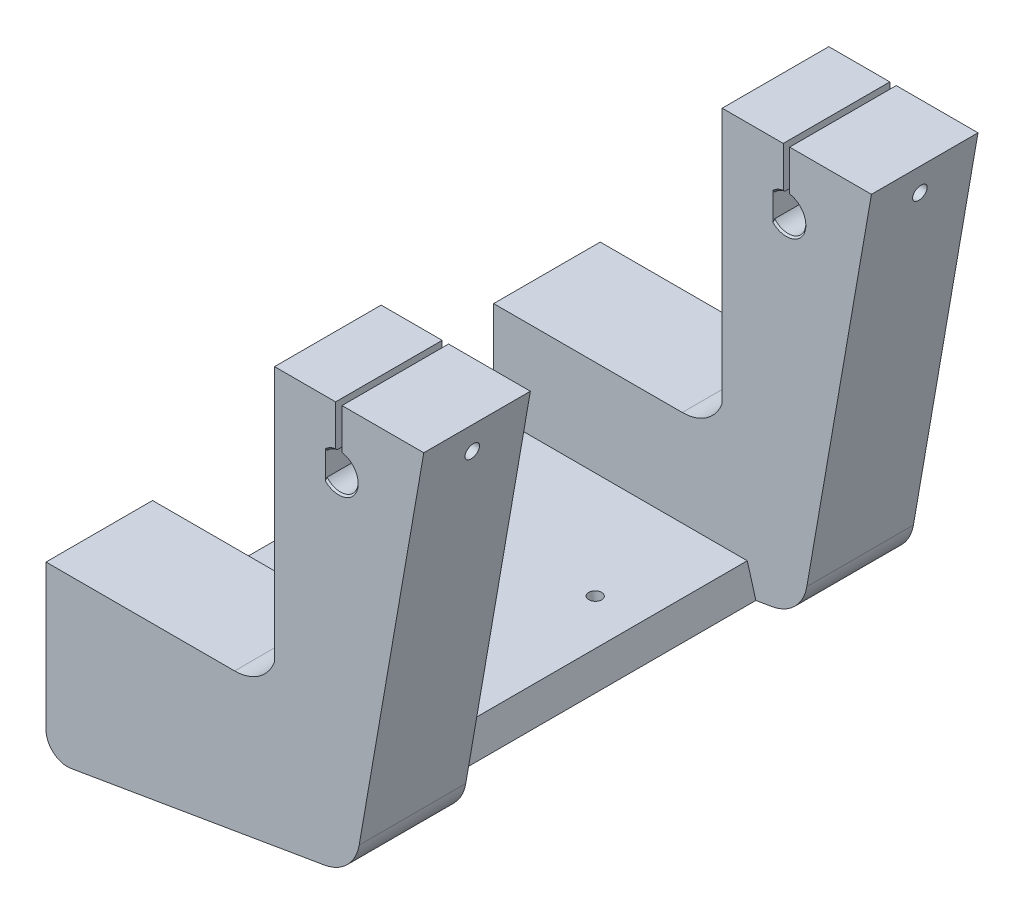
from build123d import *

# Parameters (mm, degrees)
BOSS_EXTRUDE1_DEPTH = 65
CUT_EXTRUDE1_DEPTH  = 40
CUT_EXTRUDE4_DEPTH  = 22.5
SKETCH11_W          = 20
SKETCH11_H          = 25
BOSS_EXTRUDE2_DEPTH = 10
BOSS_EXTRUDE6_DEPTH = 25
BOSS_EXTRUDE7_DEPTH = 25
CUT_EXTRUDE16_DEPTH = 130
SKETCH27_R          = 1.5
CUT_EXTRUDE17_DEPTH = 50
SKETCH28_R          = 1.7
CUT_EXTRUDE18_DEPTH = 50
BOSS_EXTRUDE8_DEPTH = 25
BOSS_EXTRUDE9_DEPTH = 25
CHAMFER9_SIZE       = 0.4
SKETCH31_R          = 1.5
CUT_EXTRUDE19_DEPTH = 10
FILLET1_R           = 0.2


with BuildPart() as part:
    # Sketch1 → Boss-Extrude1 (new body, symmetric)
    with BuildSketch(Plane.XY):
        with BuildLine():
            Line((0, 0), (0, -25.554938316))
            ThreePointArc((0, -25.554938316), (-2.359933303, -32.007021768), (-8.325876175, -35.413807897))
            Line((-8.325876175, -35.413807897), (-67.775097409, -45.508814922))
            ThreePointArc((-67.775097409, -45.508814922), (-71.838201048, -44.399413479), (-73.612159322, -40.579380131))
            Line((-73.612159322, -40.579380131), (-73.612159322, -6.5))
            Line((-73.612159322, -6.5), (-29.367881905, -6.5))
            ThreePointArc((-29.367881905, -6.5), (-23.632117541, -4.691520443), (-19.970955697, 0.079798567))
            Line((-19.970955697, 0.079798567), (-20, 0))
            Line((-20, 0), (0, 0))
        make_face()
    extrude(amount=BOSS_EXTRUDE1_DEPTH, both=True)

    # Sketch2 → Cut-Extrude1 (cut, symmetric)
    with BuildSketch(Plane.XY):
        with BuildLine():
            Line((-20, 0), (-19.970955697, 0.079798567))
            ThreePointArc((-19.970955697, 0.079798567), (-20.672372291, -1.438432196), (-21.617003148, -2.818534521))
            Line((-21.617003148, -2.818534521), (-12.102051753, -36.055036129))
            Line((-12.102051753, -36.055036129), (-8.325876175, -35.413807897))
            ThreePointArc((-8.325876175, -35.413807897), (-2.359933303, -32.007021768), (0, -25.554938316))
            Line((0, -25.554938316), (0, 0))
            Line((0, 0), (-20, 0))
        make_face()
    extrude(amount=CUT_EXTRUDE1_DEPTH, both=True, mode=Mode.SUBTRACT)

    # Sketch5 → Cut-Extrude4 (cut, symmetric)
    with BuildSketch(Plane(origin=(0, -6.5, 0), x_dir=(1, 0, 0), z_dir=(0, 1, 0))):
        Polygon((-73.612159322, 40), (-29.401702386, 40), (0, 40), (0, -40), (-29.367881905, -40), (-73.612159322, -40), align=None)
    extrude(amount=CUT_EXTRUDE4_DEPTH, both=True, mode=Mode.SUBTRACT)

    # Sketch11 → Boss-Extrude2 (add)
    with BuildSketch(Plane(origin=(0, 0, 0), x_dir=(1, 0, 0), z_dir=(0, 1, 0))):
        with Locations((-10, 52.5)):
            Rectangle(SKETCH11_W, SKETCH11_H)
        with Locations((-10, -52.5)):
            Rectangle(SKETCH11_W, SKETCH11_H)
    extrude(amount=BOSS_EXTRUDE2_DEPTH)

    # Sketch24 → Boss-Extrude6 (add)
    with BuildSketch(Plane(origin=(0, 0, -65), x_dir=(-1, 0, 0), z_dir=(0, 0, -1))):
        Polygon((0.147326036, -27.265147592), (-15, 60), (20, 60), (20, 0.001030349), align=None)
    extrude(amount=-BOSS_EXTRUDE6_DEPTH)

    # Sketch25 → Boss-Extrude7 (add)
    with BuildSketch(Plane.XY.offset(65)):
        Polygon((-0.147326036, -27.265147592), (-20, 0.001030349), (-20, 60), (15, 60), align=None)
    extrude(amount=-BOSS_EXTRUDE7_DEPTH)

    # Sketch26 → Cut-Extrude16 (cut)
    with BuildSketch(Plane(origin=(0, 0, -65), x_dir=(-1, 0, 0), z_dir=(0, 0, -1))):
        with BuildLine():
            Line((4.180094607, 50.081666326), (4.180094607, 61.21751544))
            Line((4.180094607, 61.21751544), (5.680094607, 61.21751544))
            Line((5.680094607, 61.21751544), (5.680094607, 50.081666326))
            ThreePointArc((5.680094607, 50.081666326), (4.930094607, 41.85), (4.180094607, 50.081666326))
        make_face()
    extrude(amount=-CUT_EXTRUDE16_DEPTH, mode=Mode.SUBTRACT)

    # Sketch27 → Cut-Extrude17 (cut)
    with BuildSketch(Plane.ZY.offset(20)):
        with Locations((-52.5, 53.5)):
            Circle(SKETCH27_R)
        with Locations((52.5, 53.5)):
            Circle(SKETCH27_R)
    extrude(amount=-CUT_EXTRUDE17_DEPTH, mode=Mode.SUBTRACT)

    # Sketch28 → Cut-Extrude18 (cut)
    with BuildSketch(Plane.ZY.offset(4.180094607)):
        with Locations((52.5, 53.5)):
            Circle(SKETCH28_R)
        with Locations((-52.5, 53.5)):
            Circle(SKETCH28_R)
    extrude(amount=-CUT_EXTRUDE18_DEPTH, mode=Mode.SUBTRACT)

    # Sketch29 → Boss-Extrude8 (add)
    with BuildSketch(Plane.XY.offset(65)):
        with BuildLine():
            Line((-8.080094607, 43.298148783), (-8.080094607, 48.701851217))
            ThreePointArc((-8.080094607, 48.701851217), (-9.080094607, 46), (-8.080094607, 43.298148783))
        make_face()
    extrude(amount=-BOSS_EXTRUDE8_DEPTH)

    # Sketch30 → Boss-Extrude9 (add)
    with BuildSketch(Plane.XY.offset(-40)):
        with BuildLine():
            Line((-8.080094607, 48.701851217), (-8.080094607, 43.298148783))
            ThreePointArc((-8.080094607, 43.298148783), (-9.080094607, 46), (-8.080094607, 48.701851217))
        make_face()
    extrude(amount=-BOSS_EXTRUDE9_DEPTH)

    # Chamfer9
    chamfer9_edges = [part.edges().sort_by_distance(p)[0] for p in [
        (-6.998541472, 49.597780922, 40),
        (-6.998541472, 49.597780922, -40),
        (-1.332313684, 43.931553135, -65),
        (-6.998541472, 49.597780922, 65),
        (-20, 53.5, -54),
        (-20, 53.5, 51),
        (-4.180094607, 53.5, 50.8),
        (-4.180094607, 53.5, -54.2),
        (-1.332313684, 43.931553135, 65),
        (-1.332313684, 43.931553135, 40),
        (-1.332313684, 43.931553135, -40),
        (-6.998541472, 49.597780922, -65),
    ]]
    chamfer(chamfer9_edges, length=CHAMFER9_SIZE)

    # Sketch31 → Cut-Extrude19 (cut)
    with BuildSketch(Plane(origin=(5.611689276, -33.047085202, 0), x_dir=(0.985886958, 0.167412383, 0), z_dir=(0.167412383, -0.985886958, 0))):
        with Locations((-29.287203222, 15)):
            Circle(SKETCH31_R)
        with Locations((-29.287203222, -15)):
            Circle(SKETCH31_R)
        with Locations((-59.287203222, -15)):
            Circle(SKETCH31_R)
        with Locations((-59.287203222, 15)):
            Circle(SKETCH31_R)
    extrude(amount=-CUT_EXTRUDE19_DEPTH, mode=Mode.SUBTRACT)

    # Fillet1
    fillet1_edges = [part.edges().sort_by_distance(p)[0] for p in [
        (-54.317621601, -43.223615721, 15),
        (-54.317621601, -43.223615721, -15),
        (-24.741012857, -38.201244245, -15),
        (-24.741012857, -38.201244245, 15),
    ]]
    fillet(fillet1_edges, radius=FILLET1_R)


solid = part.part
